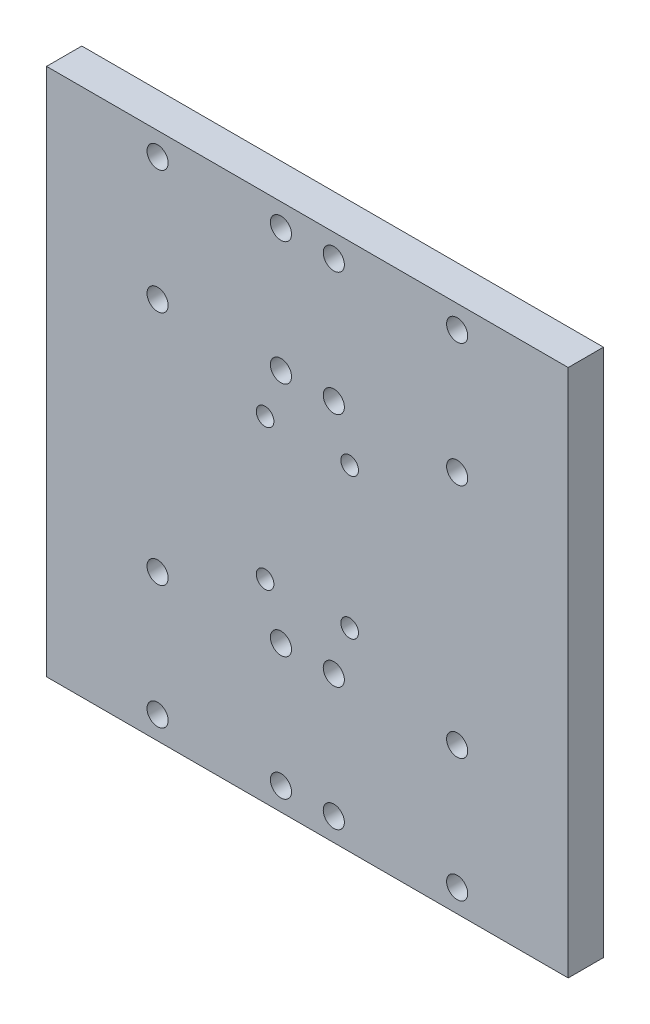
from build123d import *

# Parameters (mm, degrees)
SKETCH1_W           = 148
SKETCH1_H           = 150
BOSS_EXTRUDE1_DEPTH = 10
SKETCH2_R           = 3
SKETCH2_R_2         = 2.5
CUT_EXTRUDE1_DEPTH  = 11


with BuildPart() as part:
    # Sketch1 → Boss-Extrude1 (new body)
    with BuildSketch(Plane.XY):
        Rectangle(SKETCH1_W, SKETCH1_H)
    extrude(amount=BOSS_EXTRUDE1_DEPTH)

    # Sketch2 → Cut-Extrude1 (cut, through all)
    with BuildSketch(Plane.XY.offset(10)):
        with Locations((-42.5, 68.5)):
            Circle(SKETCH2_R)
        with Locations((-42.5, 33.5)):
            Circle(SKETCH2_R)
        with Locations((42.5, 33.5)):
            Circle(SKETCH2_R)
        with Locations((42.5, 68.5)):
            Circle(SKETCH2_R)
        with Locations((-7.5, 68.5)):
            Circle(SKETCH2_R)
        with Locations((7.5, 68.5)):
            Circle(SKETCH2_R)
        with Locations((-7.5, 33.5)):
            Circle(SKETCH2_R)
        with Locations((7.5, 33.5)):
            Circle(SKETCH2_R)
        with Locations((-12, 20)):
            Circle(SKETCH2_R_2)
        with Locations((12, 20)):
            Circle(SKETCH2_R_2)
        with Locations((12, -20)):
            Circle(SKETCH2_R_2)
        with Locations((-12, -20)):
            Circle(SKETCH2_R_2)
        with Locations((7.5, -33.5)):
            Circle(SKETCH2_R)
        with Locations((-7.5, -33.5)):
            Circle(SKETCH2_R)
        with Locations((7.5, -68.5)):
            Circle(SKETCH2_R)
        with Locations((-7.5, -68.5)):
            Circle(SKETCH2_R)
        with Locations((42.5, -68.5)):
            Circle(SKETCH2_R)
        with Locations((42.5, -33.5)):
            Circle(SKETCH2_R)
        with Locations((-42.5, -33.5)):
            Circle(SKETCH2_R)
        with Locations((-42.5, -68.5)):
            Circle(SKETCH2_R)
    extrude(amount=-CUT_EXTRUDE1_DEPTH, mode=Mode.SUBTRACT)


solid = part.part
